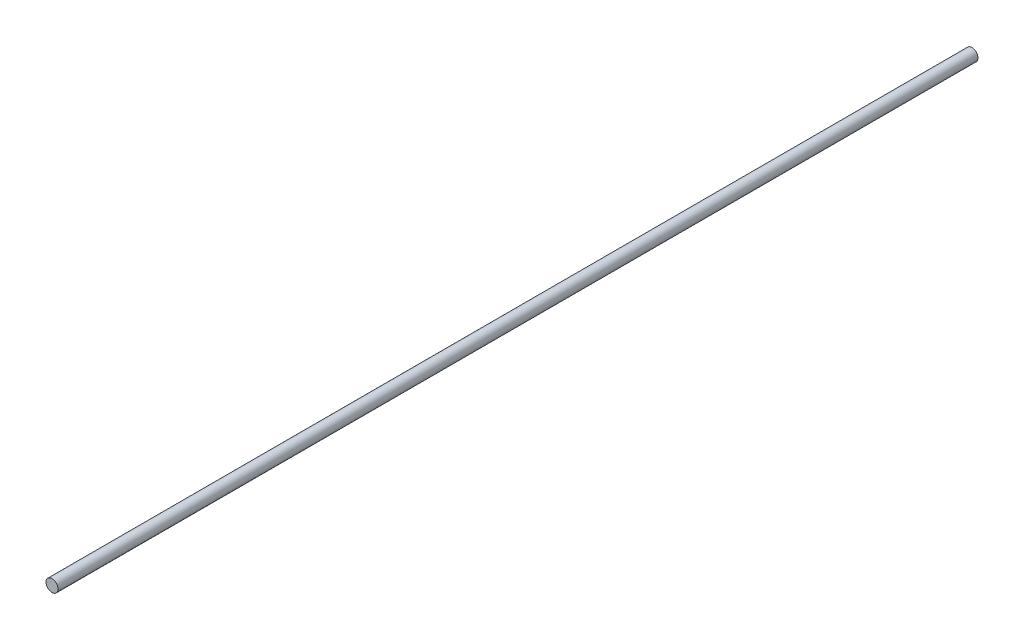
from build123d import *

# Parameters (mm, degrees)
CROQUIS1_R              = 3.5
SALIENTE_EXTRUIR1_DEPTH = 535


with BuildPart() as part:
    # Croquis1 → Saliente-Extruir1 (new body)
    with BuildSketch(Plane.XY):
        Circle(CROQUIS1_R)
    extrude(amount=SALIENTE_EXTRUIR1_DEPTH)


solid = part.part
